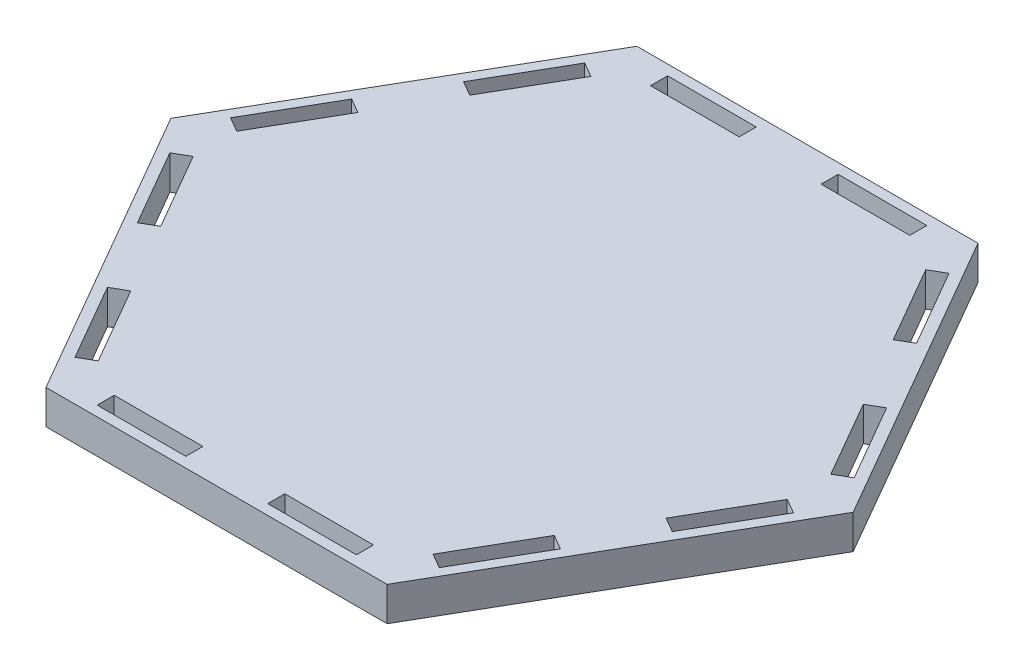
from build123d import *

# Parameters (mm, degrees)
BOSS_EXTRUDE1_DEPTH = 6.35
SKETCH2_W           = 16.51
SKETCH2_H           = 3.175
CUT_EXTRUDE1_DEPTH  = 7.35


with BuildPart() as part:
    # Sketch1 → Boss-Extrude1 (new body)
    with BuildSketch(Plane(origin=(0, 0, 0), x_dir=(1, 0, 0), z_dir=(0, 1, 0))):
        Polygon((-63.5, 0), (-31.75, -54.99261314), (31.75, -54.99261314), (63.5, 0), (31.75, 54.99261314), (-31.75, 54.99261314), align=None)
    extrude(amount=BOSS_EXTRUDE1_DEPTH)

    # Sketch2 → Cut-Extrude1 (cut, through all)
    with BuildSketch(Plane(origin=(0, 6.35, 0), x_dir=(1, 0, 0), z_dir=(0, 1, 0))):
        Polygon((-55.290590949, -4.059113577), (-58.040221606, -5.646613577), (-49.785221606, -19.944692993), (-47.035590949, -18.357192993), align=None)
        Polygon((-31.160590949, -45.853499563), (-33.910221606, -47.440999563), (-42.165221606, -33.142920147), (-39.415590949, -31.555420147), align=None)
        Polygon((-31.160590949, 45.853499563), (-33.910221606, 47.440999563), (-42.165221606, 33.142920147), (-39.415590949, 31.555420147), align=None)
        Polygon((-49.785221606, 19.944692993), (-47.035590949, 18.357192993), (-55.290590949, 4.059113577), (-58.040221606, 5.646613577), align=None)
        with Locations((15.875, 51.50011314)):
            Rectangle(SKETCH2_W, SKETCH2_H)
        with Locations((-15.875, 51.50011314)):
            Rectangle(SKETCH2_W, SKETCH2_H)
        Polygon((55.290590949, 4.059113577), (58.040221606, 5.646613577), (49.785221606, 19.944692993), (47.035590949, 18.357192993), align=None)
        Polygon((42.165221606, 33.142920147), (39.415590949, 31.555420147), (31.160590949, 45.853499563), (33.910221606, 47.440999563), align=None)
        Polygon((31.160590949, -45.853499563), (33.910221606, -47.440999563), (42.165221606, -33.142920147), (39.415590949, -31.555420147), align=None)
        Polygon((49.785221606, -19.944692993), (47.035590949, -18.357192993), (55.290590949, -4.059113577), (58.040221606, -5.646613577), align=None)
        with Locations((-15.875, -51.50011314)):
            Rectangle(SKETCH2_W, SKETCH2_H)
        with Locations((15.875, -51.50011314)):
            Rectangle(SKETCH2_W, SKETCH2_H)
    extrude(amount=-CUT_EXTRUDE1_DEPTH, mode=Mode.SUBTRACT)


solid = part.part
